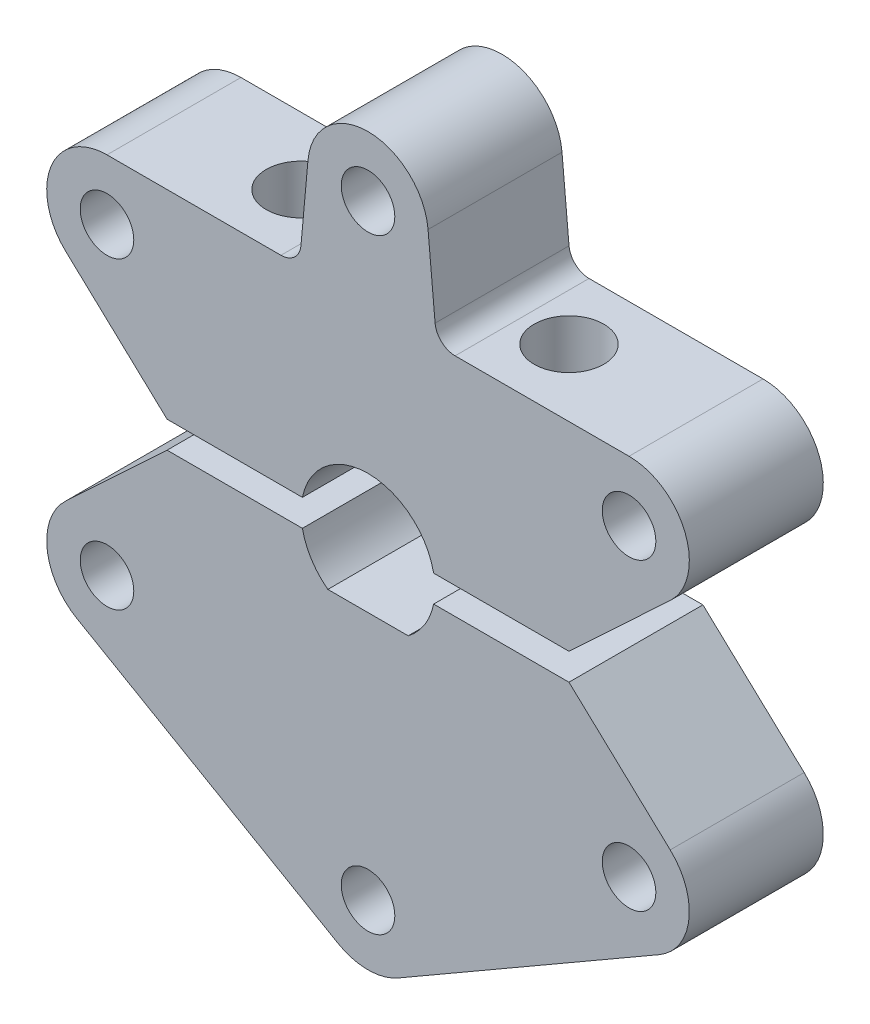
from build123d import *

# Parameters (mm, degrees)
SKETCH_1_R          = 2
EXTRUDE_1_DEPTH     = 10
EXTRUDE_1_2_DEPTH   = 10
SKETCH_2_R          = 2.6
CUT_EXTRUDE_1_DEPTH = 14.85
SKETCH_3_R          = 2
CUT_EXTRUDE_2_DEPTH = 43.95


with BuildPart() as part:
    # 草图1 → 凸台-拉伸1 (new body)
    with BuildSketch(Plane.XY):
        with BuildLine():
            Line((-3, -4), (3, -4))
            ThreePointArc((3, -4), (4.224744871, -2.674234614), (4.898979486, -1))
            Line((4.898979486, -1), (15, -1))
            Line((15, -1), (22.557859125, -8.061983991))
            ThreePointArc((22.557859125, -8.061983991), (23.956389252, -11.861653581), (21.735571585, -15.247114317))
            Line((21.735571585, -15.247114317), (2.25, -26.497114317))
            ThreePointArc((2.25, -26.497114317), (0, -27.1), (-2.25, -26.497114317))
            Line((-2.25, -26.497114317), (-21.735571585, -15.247114317))
            ThreePointArc((-21.735571585, -15.247114317), (-23.956389252, -11.861653581), (-22.557859125, -8.061983991))
            Line((-22.557859125, -8.061983991), (-15, -1))
            Line((-15, -1), (-4.898979486, -1))
            ThreePointArc((-4.898979486, -1), (-4.224744871, -2.674234614), (-3, -4))
        make_face()
        with Locations((-19.485571585, -11.35)):
            Circle(SKETCH_1_R, mode=Mode.SUBTRACT)
        with Locations((0, -22.6)):
            Circle(SKETCH_1_R, mode=Mode.SUBTRACT)
        with Locations((19.485571585, -11.35)):
            Circle(SKETCH_1_R, mode=Mode.SUBTRACT)
    extrude(amount=EXTRUDE_1_DEPTH)

    # 草图3 → 切除-拉伸2 (cut, through all)
    with BuildSketch(Plane(origin=(0, 15.85, 0), x_dir=(1, 0, 0), z_dir=(0, 1, 0))):
        with Locations((-10, -5)):
            Circle(SKETCH_3_R)
        with Locations((10, -5)):
            Circle(SKETCH_3_R)
    extrude(amount=-CUT_EXTRUDE_2_DEPTH, mode=Mode.SUBTRACT)


with BuildPart() as body_2:
    # 草图1 → Extrude 1 2 (new body)
    with BuildSketch(Plane.XY):
        with BuildLine():
            Line((-15, 1), (-22.557859125, 8.061983991))
            ThreePointArc((-22.557859125, 8.061983991), (-23.671624143, 13.001352167), (-19.485571585, 15.85))
            Line((-19.485571585, 15.85), (-6.5, 15.85))
            ThreePointArc((-6.5, 15.85), (-5.488301483, 16.242540696), (-5.006113419, 17.214711852))
            Line((-5.006113419, 17.214711852), (-4.481659743, 23.005864444))
            ThreePointArc((-4.481659743, 23.005864444), (0, 27.1), (4.481659743, 23.005864444))
            Line((4.481659743, 23.005864444), (5.006113419, 17.214711852))
            ThreePointArc((5.006113419, 17.214711852), (5.488301483, 16.242540696), (6.5, 15.85))
            Line((6.5, 15.85), (19.485571585, 15.85))
            ThreePointArc((19.485571585, 15.85), (23.671624143, 13.001352167), (22.557859125, 8.061983991))
            Line((22.557859125, 8.061983991), (15, 1))
            Line((15, 1), (4.898979486, 1))
            ThreePointArc((4.898979486, 1), (0, 5), (-4.898979486, 1))
            Line((-4.898979486, 1), (-15, 1))
        make_face()
        with Locations((-19.485571585, 11.35)):
            Circle(SKETCH_1_R, mode=Mode.SUBTRACT)
        with Locations((0, 22.6)):
            Circle(SKETCH_1_R, mode=Mode.SUBTRACT)
        with Locations((19.485571585, 11.35)):
            Circle(SKETCH_1_R, mode=Mode.SUBTRACT)
    extrude(amount=EXTRUDE_1_2_DEPTH)

    # 草图2 → 切除-拉伸1 (cut)
    with BuildSketch(Plane(origin=(0, 15.85, 0), x_dir=(1, 0, 0), z_dir=(0, 1, 0))):
        with Locations((-10, -5)):
            Circle(SKETCH_2_R)
        with Locations((10, -5)):
            Circle(SKETCH_2_R)
    extrude(amount=-CUT_EXTRUDE_1_DEPTH, mode=Mode.SUBTRACT)


solid = Compound([part.part, body_2.part])
